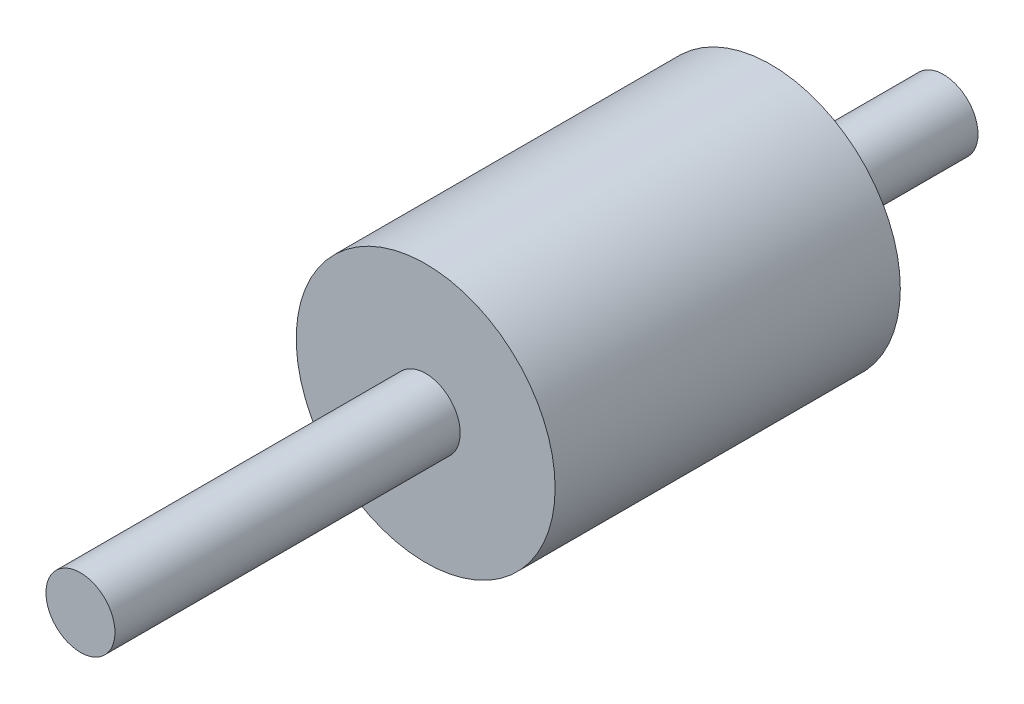
from build123d import *

# Parameters (mm, degrees)
SKETCH1_R                = 7.5
BOSS_EXTRUDE1_DEPTH      = 20
SKETCH2_R                = 1
BOSS_EXTRUDE3_DEPTH      = 40
BOSS_EXTRUDE3_DEPTH_BACK = 10
SKETCH3_R                = 2
BOSS_EXTRUDE4_DEPTH      = 40
BOSS_EXTRUDE4_DEPTH_BACK = 10


with BuildPart() as part:
    # Sketch1 → Boss-Extrude1 (new body)
    with BuildSketch(Plane.XY):
        Circle(SKETCH1_R)
    extrude(amount=BOSS_EXTRUDE1_DEPTH)

    # Sketch2 → Boss-Extrude3 (add, two sides)
    with BuildSketch(Plane.XY) as boss_extrude3_sk:
        Circle(SKETCH2_R)
    extrude(amount=BOSS_EXTRUDE3_DEPTH)
    extrude(boss_extrude3_sk.sketch, amount=-BOSS_EXTRUDE3_DEPTH_BACK)

    # Sketch3 → Boss-Extrude4 (add, two sides)
    with BuildSketch(Plane.XY) as boss_extrude4_sk:
        Circle(SKETCH3_R)
    extrude(amount=BOSS_EXTRUDE4_DEPTH)
    extrude(boss_extrude4_sk.sketch, amount=-BOSS_EXTRUDE4_DEPTH_BACK)


solid = part.part
